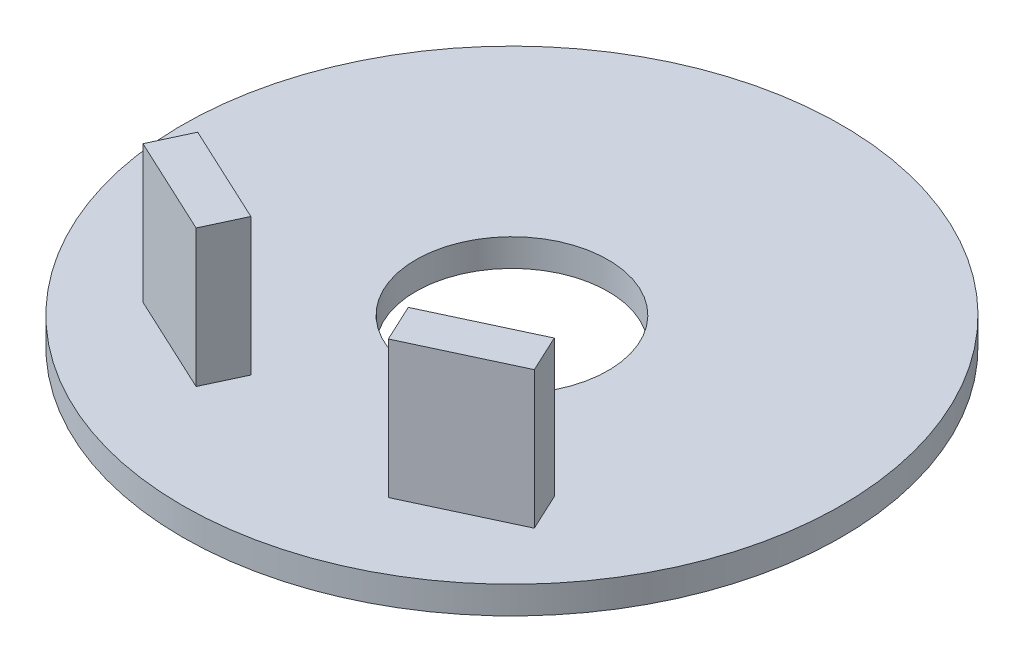
from build123d import *

# Parameters (mm, degrees)
SKETCH1_R           = 12
SKETCH1_R_2         = 3.5
BOSS_EXTRUDE1_DEPTH = 0.5
BOSS_EXTRUDE3_DEPTH = 5


with BuildPart() as part:
    # Sketch1 → Boss-Extrude1 (new body, symmetric)
    with BuildSketch(Plane(origin=(0, 0, 0), x_dir=(1, 0, 0), z_dir=(0, 1, 0))):
        Circle(SKETCH1_R)
        Circle(SKETCH1_R_2, mode=Mode.SUBTRACT)
    extrude(amount=BOSS_EXTRUDE1_DEPTH, both=True)

    # Sketch5 → Boss-Extrude3 (add)
    with BuildSketch(Plane(origin=(0, 0.5, 0), x_dir=(1, 0, 0), z_dir=(0, 1, 0))):
        Polygon((-6.491303756, -4.950065272), (-2.866072607, -6.640538319), (-3.5, -8), (-7.125231148, -6.309526953), align=None)
        Polygon((7.125231148, -6.309526953), (6.491303756, -4.950065272), (2.866072607, -6.640538319), (3.5, -8), align=None)
    extrude(amount=BOSS_EXTRUDE3_DEPTH)


solid = part.part
